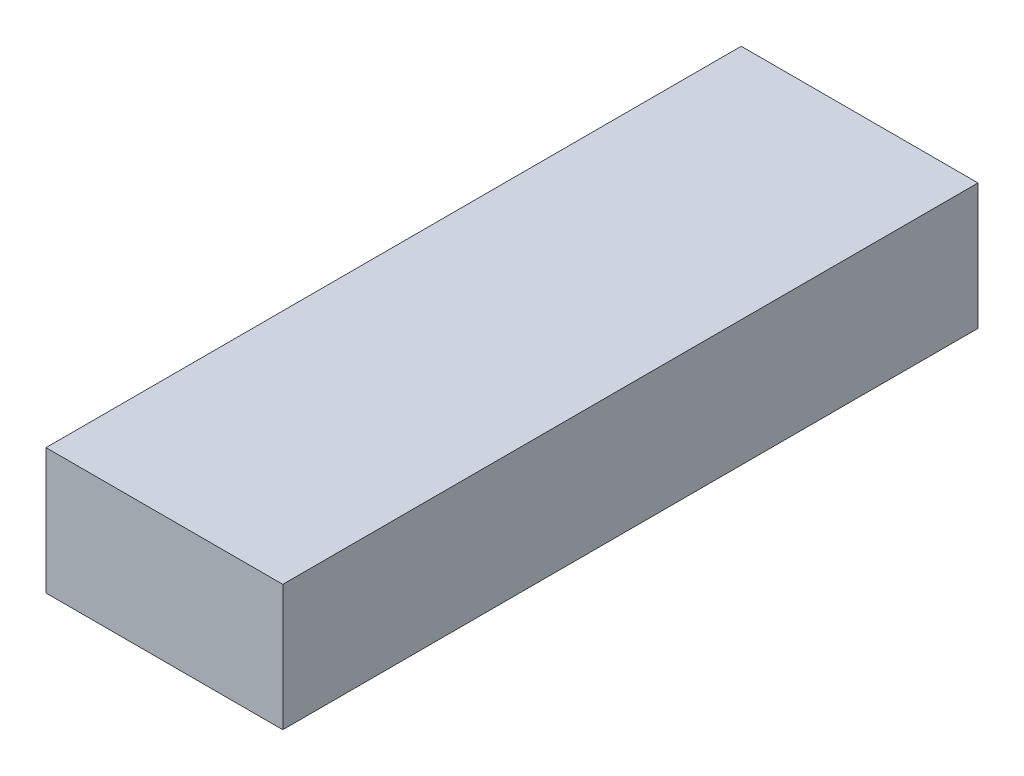
from build123d import *

# Parameters (mm, degrees)
SKETCH1_W           = 47
SKETCH1_H           = 138
BOSS_EXTRUDE1_DEPTH = 25


with BuildPart() as part:
    # Sketch1 → Boss-Extrude1 (new body)
    with BuildSketch(Plane(origin=(0, 0, 0), x_dir=(1, 0, 0), z_dir=(0, 1, 0))):
        Rectangle(SKETCH1_W, SKETCH1_H)
    extrude(amount=BOSS_EXTRUDE1_DEPTH)


solid = part.part
